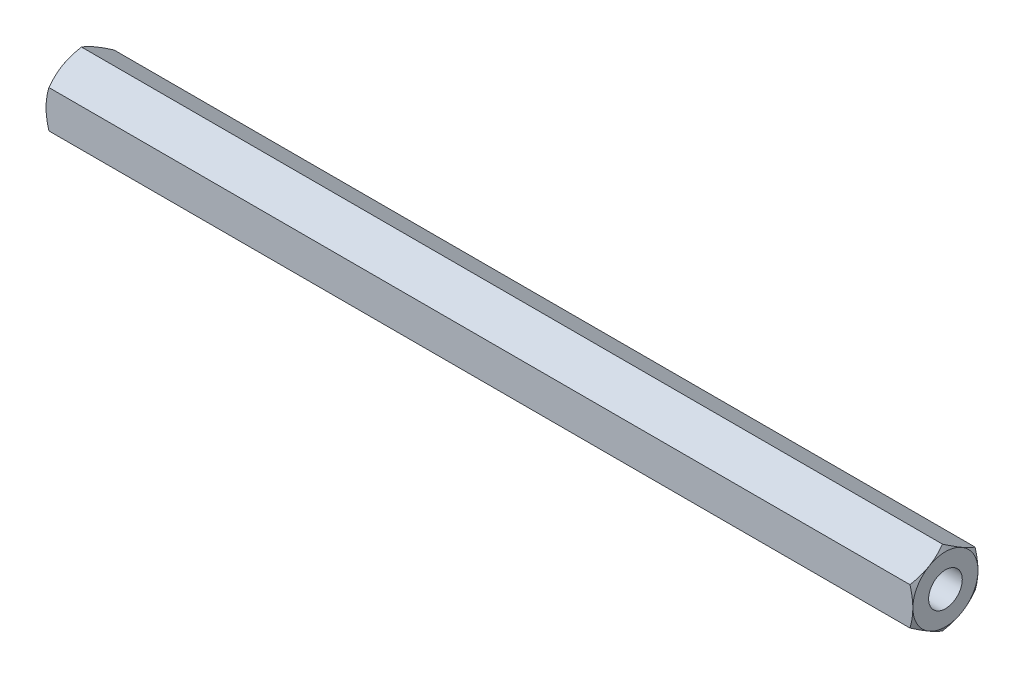
from build123d import *

# Parameters (mm, degrees)
BOSS_EXTRUDE1_DEPTH = 106.5
TAP1_D              = 4.134
TAP1_DEPTH          = 12.4
TAP1_TIP            = 1.2419789
TAP2_D              = 4.134
TAP2_DEPTH          = 12.4
TAP2_TIP            = 1.2419789


with BuildPart() as part:
    # Sketch1 → Boss-Extrude1 (new body)
    with BuildSketch(Plane(origin=(0, 0, 0), x_dir=(0, 0, -1), z_dir=(1, 0, 0))):
        Polygon((0, -4.618802154), (4, -2.309401077), (4, 2.309401077), (0, 4.618802154), (-4, 2.309401077), (-4, -2.309401077), align=None)
    extrude(amount=BOSS_EXTRUDE1_DEPTH)

    # Sketch2 → Cut-Revolve1 (revolve, cut)
    with BuildSketch(Plane.XY):
        Polygon((0, 4.618802154), (0.35726559, 4.618802154), (0, 4), align=None)
        Polygon((106.14273441, 4.618802154), (106.5, 4), (106.5, 4.618802154), align=None)
    revolve(axis=Axis((0, 0, 0), (1, 0, 0)), mode=Mode.SUBTRACT)

    # Tap1
    with Locations(Plane.ZY):
        with Locations((0, 0)):
            Hole(TAP1_D / 2, depth=TAP1_DEPTH)
            with Locations((0, 0, -(TAP1_DEPTH + TAP1_TIP / 2))):  # 118° drill point
                Cone(0, TAP1_D / 2, TAP1_TIP, mode=Mode.SUBTRACT)

    # Tap2
    with Locations(Plane(origin=(106.5, 0, 0), x_dir=(0, 0, -1), z_dir=(1, 0, 0))):
        with Locations((0, 0)):
            Hole(TAP2_D / 2, depth=TAP2_DEPTH)
            with Locations((0, 0, -(TAP2_DEPTH + TAP2_TIP / 2))):  # 118° drill point
                Cone(0, TAP2_D / 2, TAP2_TIP, mode=Mode.SUBTRACT)


solid = part.part
